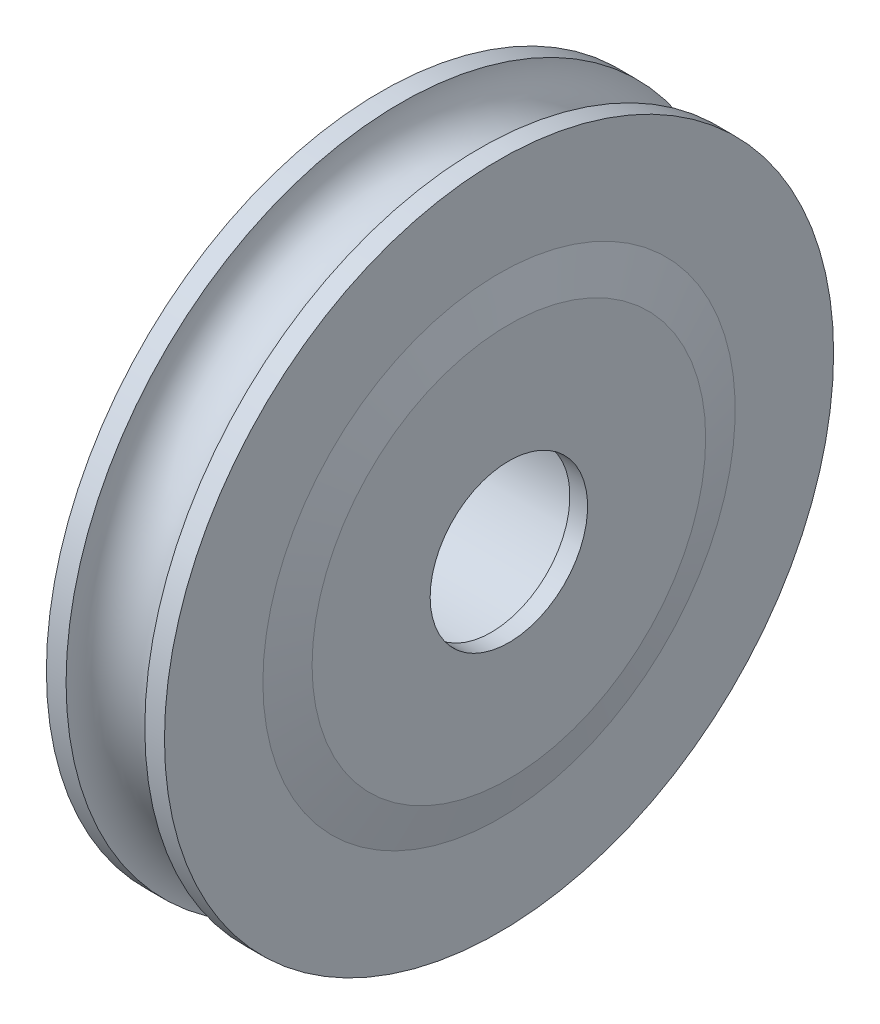
from build123d import *


with BuildPart() as part:
    # 草图1 → 旋转1 (revolve)
    with BuildSketch(Plane.XY):
        with BuildLine():
            Line((5.6, 5.1), (5.6, 4))
            Line((5.6, 4), (6.5, 4))
            Line((6.5, 4), (6.5, 10))
            Line((6.5, 10), (6, 12))
            Line((6, 12), (6, 17))
            Line((6, 17), (5, 17))
            ThreePointArc((5, 17), (3, 14.990135067), (1, 17))
            Line((1, 17), (0, 17))
            Line((0, 17), (0, 5.1))
            Line((0, 5.1), (5.6, 5.1))
        make_face()
    revolve(axis=Axis((0, 0, 0), (1, 0, 0)))


solid = part.part
